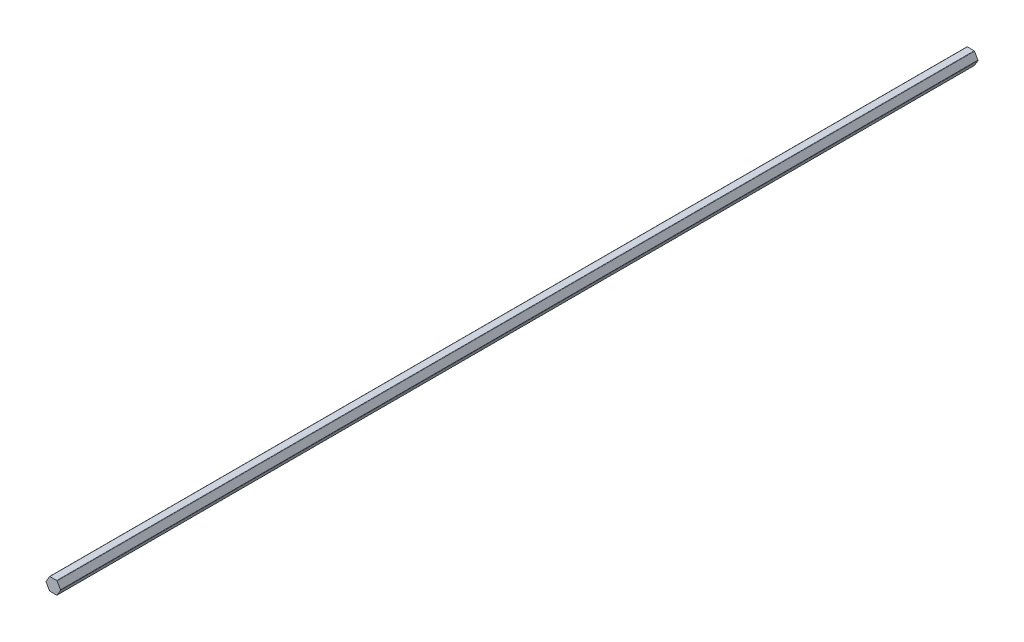
from build123d import *

# Parameters (mm, degrees)
BOSS_EXTRUDE1_DEPTH = 457.2
FILLET1_R           = 0.508


with BuildPart() as part:
    # Sketch1 → Boss-Extrude1 (new, symmetric)
    with BuildSketch(Plane.XY):
        Polygon((7.332348419, 0), (3.666174209, 6.35), (-3.666174209, 6.35), (-7.332348419, 0), (-3.666174209, -6.35), (3.666174209, -6.35), align=None)
    extrude(amount=BOSS_EXTRUDE1_DEPTH, both=True)

    # Fillet1
    fillet1_edges = [part.edges().sort_by_distance(p)[0] for p in [
        (-3.666174209, -6.35, 0),
        (-7.332348419, 0, 0),
        (3.666174209, -6.35, 0),
        (7.332348419, 0, 0),
        (-3.666174209, 6.35, 0),
        (3.666174209, 6.35, 0),
    ]]
    fillet(fillet1_edges, radius=FILLET1_R)


solid = part.part
